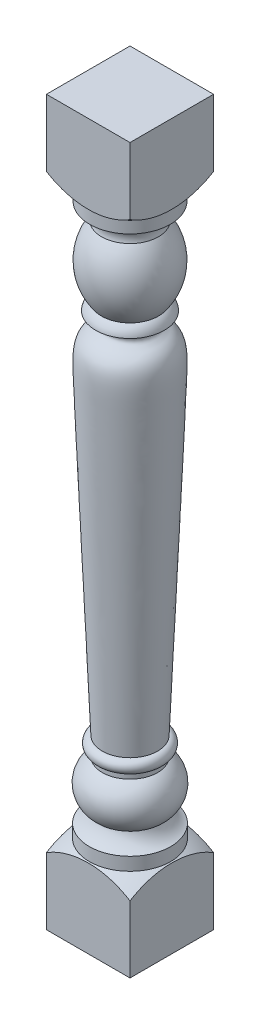
from build123d import *

# Parameters (mm, degrees)
SKETCH4_OUTSIDE_W       = 568.745
SKETCH4_OUTSIDE_H       = 568.744
SKETCH4_OUTSIDE_W_2     = 142.875
SKETCH4_OUTSIDE_H_2     = 142.875
CUT_EXTRUDE2_DEPTH      = 1102.137097563
CUT_EXTRUDE2_DEPTH_BACK = 136.613389618
SCALE1_SCALE            = 0.4


with BuildPart() as part:
    # Sketch2 → Revolve2 (revolve)
    with BuildSketch(Plane.XY):
        with BuildLine():
            Line((0, -135.613389618), (71.4375, -135.613389618))
            Line((71.4375, -135.613389618), (71.4375, 1101.137097563))
            Line((71.4375, 1101.137097563), (0, 1101.137097563))
            Line((0, 1101.137097563), (-80.9625, 1101.137097563))
            ThreePointArc((-80.9625, 1101.137097563), (-58.419611858, 1021.369369126), (2.54, 965.2))
            Line((2.54, 965.2), (2.54, 942.975))
            ThreePointArc((2.54, 942.975), (19.833806838, 933.760429307), (22.86, 914.4))
            ThreePointArc((22.86, 914.4), (2.54, 855.6625), (22.86, 796.925))
            ThreePointArc((22.86, 796.925), (16.116640845, 790.052049859), (12.7, 781.05))
            add(Edge.make_bspline(
                [(12.7, 781.05), (28.543276087, 778.212494125), (43.256272949, 750.690215213), (-0.0352258, 758.012837994), (6.586319301, 584.753689168), (4.683111774, 626.517341683), (24.13, 152.4)],
                knots=[0, 0, 0, 0, 0.11708426, 0.342939455, 0.431231029, 1, 1, 1, 1], degree=3))
            ThreePointArc((24.13, 152.4), (13.97, 141.2875), (24.13, 130.175))
            Line((24.13, 130.175), (24.13, 120.65))
            ThreePointArc((24.13, 120.65), (1.440144638, 82.917580923), (22.86, 44.45))
            ThreePointArc((22.86, 44.45), (14.760476333, 31.095408029), (1.905, 22.225))
            Line((1.905, 22.225), (1.905, 0))
            ThreePointArc((1.905, 0), (-58.605787024, -56.149539347), (-80.9625, -135.613389618))
            Line((-80.9625, -135.613389618), (0, -135.613389618))
        make_face()
    revolve(axis=Axis((71.4375, -135.613389618, 0), (0, 1, 0)))

    # Sketch4 outside → Cut-Extrude2 (cut, two sides)
    with BuildSketch(Plane(origin=(0, 0, 0), x_dir=(1, 0, 0), z_dir=(0, 1, 0))) as cut_extrude2_sk:
        with Locations((71.4375, 0)):
            Rectangle(SKETCH4_OUTSIDE_W, SKETCH4_OUTSIDE_H)
        with Locations((71.4375, 0)):
            Rectangle(SKETCH4_OUTSIDE_W_2, SKETCH4_OUTSIDE_H_2, mode=Mode.SUBTRACT)
    extrude(amount=CUT_EXTRUDE2_DEPTH, mode=Mode.SUBTRACT)
    extrude(cut_extrude2_sk.sketch, amount=-CUT_EXTRUDE2_DEPTH_BACK, mode=Mode.SUBTRACT)


with BuildPart() as part_1:
    # Scale1: scaled about (0, 0, 0)
    add(part.part.scale(SCALE1_SCALE))


solid = part_1.part
